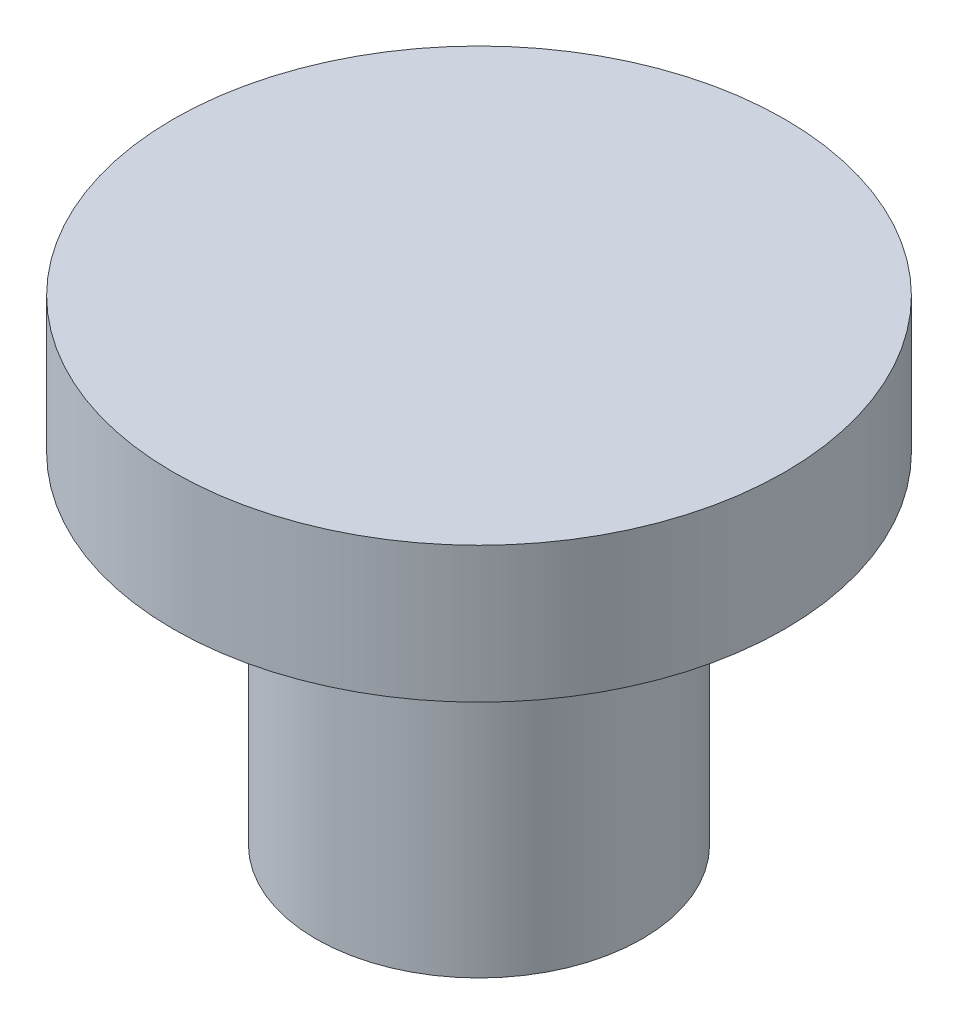
from build123d import *

# Parameters (mm, degrees)
SKETCH1_R           = 3.048
BOSS_EXTRUDE1_DEPTH = 6.35
SKETCH2_R           = 5.715
BOSS_EXTRUDE2_DEPTH = 2.54


with BuildPart() as part:
    # Sketch1 → Boss-Extrude1 (new body)
    with BuildSketch(Plane(origin=(0, 0, 0), x_dir=(1, 0, 0), z_dir=(0, 1, 0))):
        Circle(SKETCH1_R)
    extrude(amount=BOSS_EXTRUDE1_DEPTH)

    # Sketch2 → Boss-Extrude2 (add)
    with BuildSketch(Plane(origin=(0, 6.35, 0), x_dir=(1, 0, 0), z_dir=(0, 1, 0))):
        Circle(SKETCH2_R)
    extrude(amount=BOSS_EXTRUDE2_DEPTH)


solid = part.part
